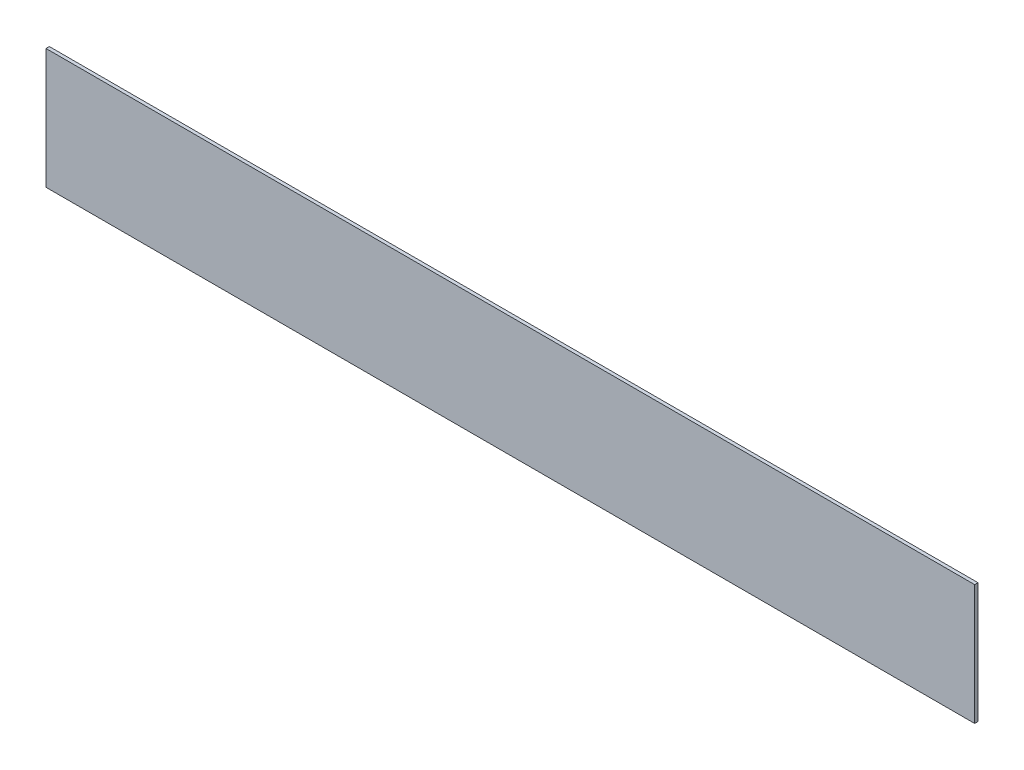
from build123d import *

# Parameters (mm, degrees)
SKETCH1_W           = 7061.2
SKETCH1_H           = 914.4
BOSS_EXTRUDE1_DEPTH = 25.4


with BuildPart() as part:
    # Sketch1 → Boss-Extrude1 (new body)
    with BuildSketch(Plane.XY):
        with Locations((3530.6, -457.2)):
            Rectangle(SKETCH1_W, SKETCH1_H)
    extrude(amount=BOSS_EXTRUDE1_DEPTH)


solid = part.part
